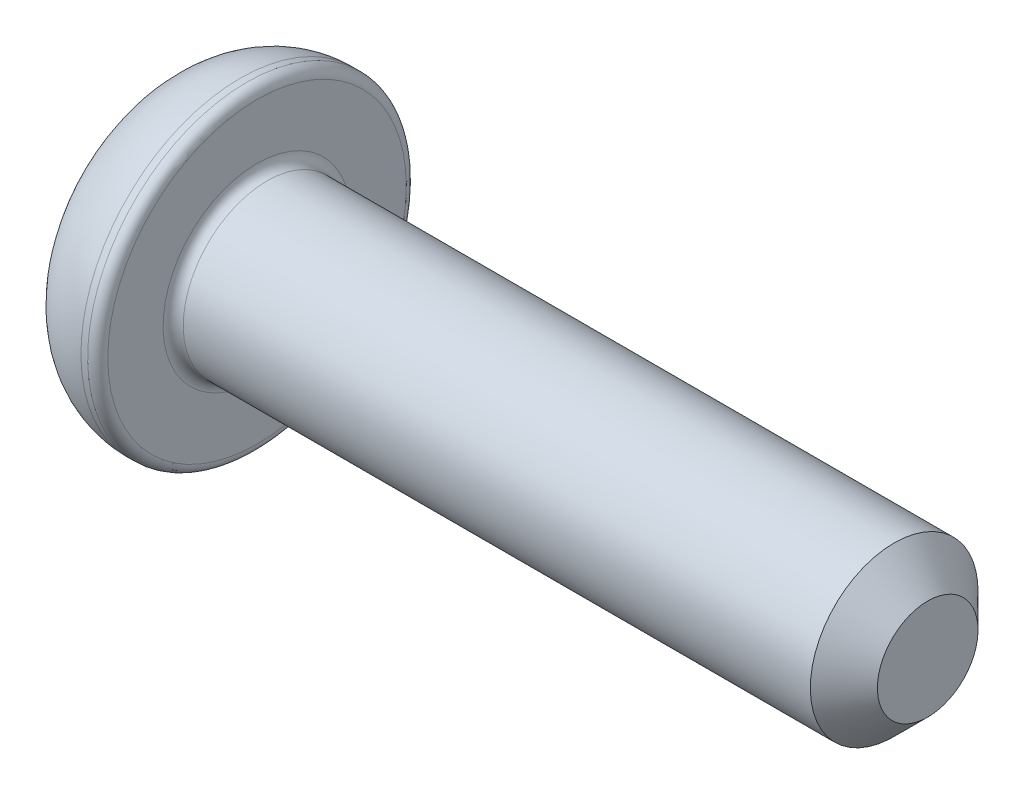
from build123d import *

# Parameters (mm, degrees)
CUT_EXTRUDE_1_DEPTH = 1.5
FILLET_1_R          = 0.3
CHAMFER_1_SIZE      = 1


with BuildPart() as part:
    # Эскиз1 → Повернуть1 (revolve)
    with BuildSketch(Plane.XY):
        with BuildLine():
            Line((0, 0), (0, 3.625))
            ThreePointArc((0, 3.625), (0.908821487, 4.451033224), (2.1, 4.75))
            Line((2.1, 4.75), (2.6, 4.75))
            Line((2.6, 4.75), (2.6, 2.5))
            Line((2.6, 2.5), (22.6, 2.5))
            Line((22.6, 2.5), (22.6, 0))
            Line((22.6, 0), (0, 0))
        make_face()
    revolve(axis=Axis((22.6, 0, 0), (-1, 0, 0)))

    # Эскиз2 → Вырез-Вытянуть1 (cut)
    with BuildSketch(Plane.ZY):
        Polygon((0.866025404, 1.5), (-0.866025404, 1.5), (-1.732050808, 0), (-0.866025404, -1.5), (0.866025404, -1.5), (1.732050808, 0), align=None)
    extrude(amount=-CUT_EXTRUDE_1_DEPTH, mode=Mode.SUBTRACT)

    # Скругление1
    fillet_1_edges = [part.edges().sort_by_distance(p)[0] for p in [
        (2.6, -2.5, 0),
        (2.6, -4.75, 0),
    ]]
    fillet(fillet_1_edges, radius=FILLET_1_R)

    # Фаска1
    chamfer_1_edges = [part.edges().sort_by_distance(p)[0] for p in [
        (22.6, -2.5, 0),
    ]]
    chamfer(chamfer_1_edges, length=CHAMFER_1_SIZE)


solid = part.part
